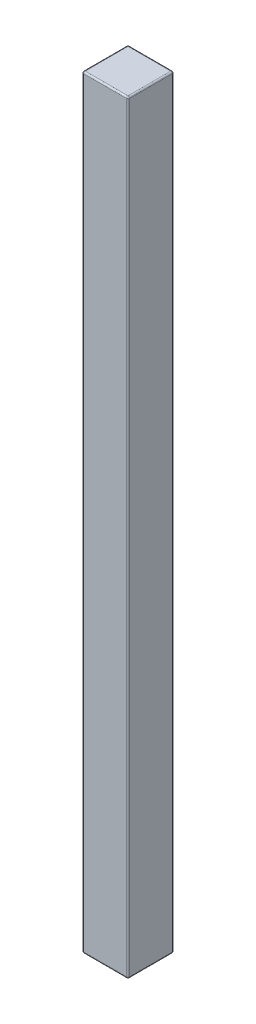
from build123d import *

# Parameters (mm, degrees)
ESQUISSE1_W        = 3
ESQUISSE1_H        = 3
BOSS_EXTRU_1_DEPTH = 50
CONG_1_R           = 0.1


with BuildPart() as part:
    # Esquisse1 → Boss.-Extru.1 (new body)
    with BuildSketch(Plane(origin=(0, 0, 0), x_dir=(1, 0, 0), z_dir=(0, 1, 0))):
        Rectangle(ESQUISSE1_W, ESQUISSE1_H)
    extrude(amount=BOSS_EXTRU_1_DEPTH)

    # Congé1
    cong_1_edges = [part.edges().sort_by_distance(p)[0] for p in [
        (-1.5, 50, 0),
        (0, 50, 1.5),
        (1.5, 50, 0),
        (0, 0, 1.5),
        (-1.5, 0, 0),
        (0, 0, -1.5),
        (1.5, 0, 0),
        (1.5, 25, 1.5),
        (-1.5, 25, 1.5),
        (-1.5, 25, -1.5),
        (1.5, 25, -1.5),
        (0, 50, -1.5),
    ]]
    fillet(cong_1_edges, radius=CONG_1_R)


solid = part.part
